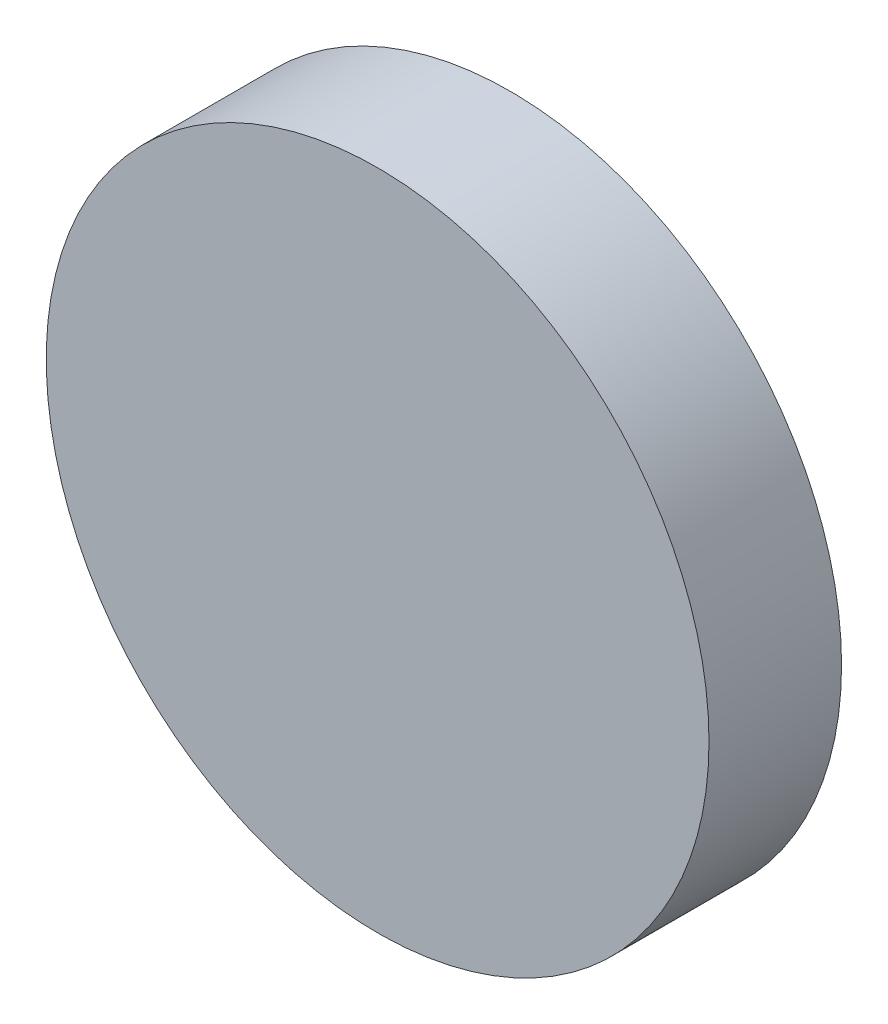
from build123d import *

# Parameters (mm, degrees)
SKETCH_1_R      = 5
EXTRUDE_1_DEPTH = 2


with BuildPart() as part:
    # 草图1 → 凸台-拉伸1 (new body)
    with BuildSketch(Plane.XY):
        Circle(SKETCH_1_R)
    extrude(amount=EXTRUDE_1_DEPTH)


solid = part.part
